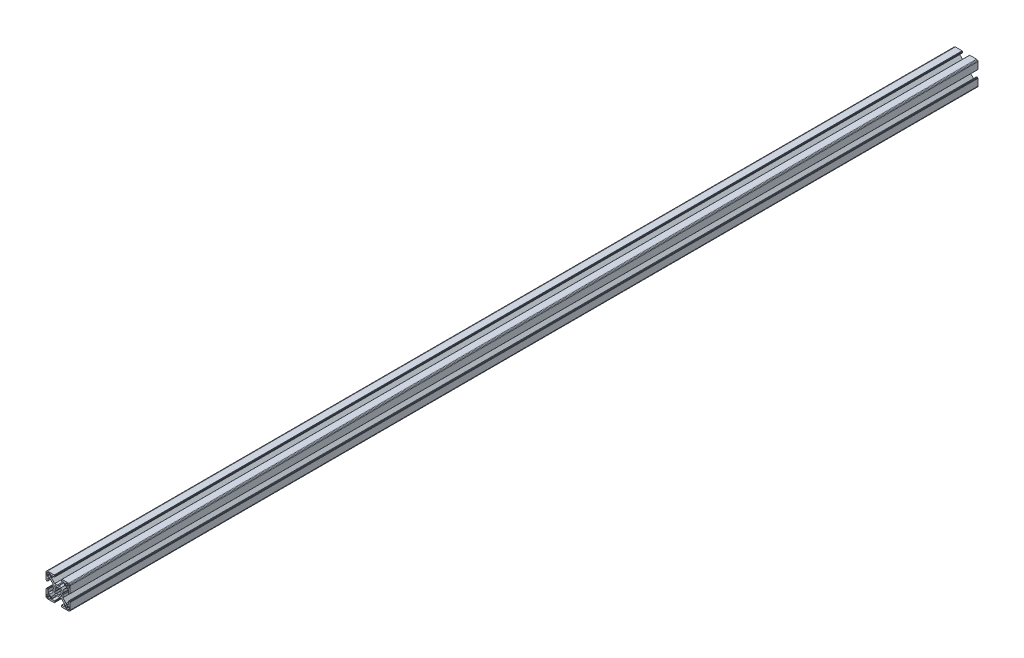
from build123d import *

# Parameters (mm, degrees)
BOSS_EXTRUDE1_DEPTH = 1130


with BuildPart() as part:
    # Sketch1 → Boss-Extrude1 (new body)
    with BuildSketch(Plane.XY):
        Polygon((28.34729664, 29.969613999), (28.000000864, 29.999999329), (19.750000909, 29.999999329), (19.715268165, 29.996961355), (19.681595266, 29.987938702), (19.649999216, 29.973205179), (19.621443003, 29.953207821), (19.596790895, 29.928557575), (19.576793537, 29.899999499), (19.562061876, 29.868405312), (19.55303736, 29.834728688), (19.549999386, 29.799999669), (19.549999386, 29.699999839), (19.546961412, 29.665268958), (19.537936896, 29.631596059), (19.523203373, 29.599998146), (19.503207877, 29.571441934), (19.478557631, 29.546789825), (19.449999556, 29.526794329), (19.418403506, 29.512060806), (19.384728745, 29.503038153), (19.349999726, 29.500000179), (19.249999896, 29.500000179), (19.215267517, 29.496958527), (19.181592755, 29.487935874), (19.149996706, 29.47320235), (19.12143863, 29.453206855), (19.096788384, 29.428554746), (19.076791026, 29.399996671), (19.062057503, 29.368402484), (19.05303485, 29.334725859), (19.049996876, 29.299998703), (19.049996876, 28.39999837), (19.059110798, 28.29580945), (19.08618062, 28.194785165), (19.13038119, 28.099997016), (19.190369539, 28.014324653), (19.264324002, 27.94037019), (19.349996366, 27.88038184), (19.444784515, 27.836181271), (19.545806937, 27.809111449), (19.650010894, 27.799984574), (23.050010706, 27.799984574), (23.084741588, 27.7969466), (23.118414487, 27.787923946), (23.150012399, 27.773190423), (23.178568612, 27.753193065), (23.203220721, 27.728542819), (23.223218079, 27.699984744), (23.237949739, 27.668386831), (23.246974255, 27.634713932), (23.25001142, 27.59998608), (23.25001142, 25.049987618), (19.204474482, 20.999982084), (15.900007876, 20.999982084), (15.000008474, 20.48483404), (14.10000814, 20.999982084), (10.795543398, 20.999982084), (7.997342887, 23.801274731), (6.750011387, 25.049984589), (6.750011387, 27.599983051), (6.753049362, 27.634713932), (6.762072946, 27.668386831), (6.776805538, 27.699984744), (6.796801965, 27.728542819), (6.821454073, 27.753193065), (6.850011218, 27.773190423), (6.881607267, 27.787923946), (6.915282029, 27.7969466), (6.950011048, 27.799984574), (10.350011791, 27.799984574), (10.45420071, 27.809098497), (10.555223133, 27.836168318), (10.650011282, 27.880368888), (10.735683645, 27.940357238), (10.809638108, 28.014311701), (10.869626458, 28.099984064), (10.913827027, 28.194772213), (10.940895918, 28.295796498), (10.950010772, 28.399985417), (10.950010772, 29.299985751), (10.946974575, 29.334739239), (10.93795065, 29.368415522), (10.923215933, 29.400009153), (10.903218427, 29.428566473), (10.878566319, 29.45321765), (10.849999264, 29.473204166), (10.818403214, 29.487937689), (10.784728453, 29.496960342), (10.749999434, 29.500000179), (10.649999604, 29.500000179), (10.615270585, 29.503038153), (10.581595823, 29.512060806), (10.549999774, 29.526794329), (10.521441698, 29.546789825), (10.496791452, 29.571441934), (10.476795025, 29.599998146), (10.462061502, 29.631596059), (10.453037918, 29.665268958), (10.449999943, 29.699999839), (10.449999943, 29.799999669), (10.446961969, 29.834728688), (10.437938385, 29.868405312), (10.423205793, 29.899999499), (10.403208435, 29.928557575), (10.378557257, 29.953207821), (10.350000113, 29.973205179), (10.318404064, 29.987938702), (10.284729302, 29.996961355), (10.250000283, 29.999999329), (1.999999397, 29.999999329), (1.652702689, 29.969613999), (1.315958682, 29.879383743), (0.999999233, 29.732050374), (0.714424066, 29.532089829), (0.467910431, 29.285576195), (0.267948955, 28.999999166), (0.120614655, 28.684040532), (0.030384399, 28.34729664), (0, 28.000000864), (0, 19.750000909), (0.003037974, 19.715268165), (0.012061559, 19.681595266), (0.026795082, 19.649999216), (0.046790577, 19.621441141), (0.071442686, 19.596789032), (0.09999983, 19.576793537), (0.13159588, 19.562060013), (0.165270641, 19.55303736), (0.19999966, 19.549999386), (0.299999461, 19.549999386), (0.334728509, 19.546959549), (0.368403242, 19.537936896), (0.399999321, 19.523203373), (0.428556465, 19.503207877), (0.453208573, 19.478555769), (0.473204069, 19.449997693), (0.487937592, 19.418403506), (0.496961176, 19.384728745), (0.499999151, 19.349999726), (0.499999151, 19.249998033), (0.503038056, 19.215269014), (0.512060709, 19.181594253), (0.526794232, 19.150000066), (0.546790194, 19.121441524), (0.571441837, 19.096789882), (0.60000029, 19.076794925), (0.631595686, 19.062061999), (0.665270619, 19.053039982), (0.700000626, 19.050000801), (1.60000096, 19.050000801), (1.704189879, 19.059116587), (1.805213233, 19.086186409), (1.90000045, 19.130385115), (1.985673745, 19.190375328), (2.059627277, 19.264327928), (2.119616325, 19.350002154), (2.163816196, 19.444788441), (2.190886018, 19.545812726), (2.200000872, 19.650001645), (2.200000872, 23.050001457), (2.203039777, 23.084732338), (2.212062431, 23.118405237), (2.226795954, 23.15000315), (2.246792381, 23.178559362), (2.271443558, 23.203211471), (2.300000702, 23.223206967), (2.331596752, 23.23794049), (2.365271513, 23.246965006), (2.400001464, 23.250001117), (4.950000857, 23.250001117), (7.997332093, 20.202670812), (8.995535423, 19.204467788), (8.995535423, 15.900001182), (9.515148227, 15.00000178), (8.995535423, 14.100002378), (8.995535423, 10.795536704), (4.950000857, 6.750002138), (2.400001464, 6.750002138), (2.365271513, 6.753040112), (2.331596752, 6.762063697), (2.300000702, 6.77679722), (2.271443558, 6.796793647), (2.246792381, 6.821444824), (2.226795954, 6.850001968), (2.212062431, 6.881598018), (2.203039777, 6.915272779), (2.200000872, 6.950002729), (2.200000872, 10.350002542), (2.190896812, 10.454174265), (2.16382699, 10.555197618), (2.119627119, 10.649984836), (2.059638071, 10.735658131), (1.985684539, 10.809611663), (1.900011244, 10.869600944), (1.805224027, 10.913800582), (1.704200673, 10.940870404), (1.600011754, 10.949986189), (0.70001142, 10.949986189), (0.665281355, 10.946948596), (0.631606253, 10.937926283), (0.600010578, 10.923193954), (0.571451747, 10.903199537), (0.546799638, 10.87854836), (0.526794232, 10.850000195), (0.512060709, 10.818404146), (0.503038056, 10.784730315), (0.499999151, 10.750000365), (0.499999151, 10.650000535), (0.496961176, 10.615270585), (0.487937592, 10.581596754), (0.473204069, 10.550000705), (0.453208573, 10.521443561), (0.428556465, 10.496791452), (0.399999321, 10.476795956), (0.368403242, 10.462062433), (0.334728509, 10.453038849), (0.299999461, 10.449999943), (0.19999966, 10.449999943), (0.165270641, 10.446961969), (0.13159588, 10.437939316), (0.09999983, 10.423205793), (0.071442686, 10.403209366), (0.046790577, 10.378558189), (0.026795082, 10.350000113), (0.012061559, 10.318404064), (0.003037974, 10.284729302), (0, 10.250000283), (0, 1.999999397), (0.030384399, 1.652702689), (0.120614655, 1.315958682), (0.267948955, 0.999999233), (0.467910431, 0.714424066), (0.714424066, 0.467910431), (0.999999233, 0.267948955), (1.315958682, 0.120614655), (1.652702689, 0.030384399), (1.999999397, 0), (10.250000283, 0), (10.284729302, 0.003037974), (10.318404064, 0.012061559), (10.350000113, 0.026795082), (10.378557257, 0.046790577), (10.403208435, 0.071442686), (10.423205793, 0.09999983), (10.437938385, 0.13159588), (10.446961969, 0.165270641), (10.449999943, 0.19999966), (10.449999943, 0.300000422), (10.453037918, 0.334729441), (10.462061502, 0.368404202), (10.476795025, 0.400000252), (10.496791452, 0.428557396), (10.521441698, 0.453208573), (10.549999774, 0.473205), (10.581595823, 0.487938523), (10.615270585, 0.496961176), (10.649999604, 0.500000082), (10.749999434, 0.500000082), (10.784728453, 0.503038056), (10.818403214, 0.512060709), (10.849999264, 0.526794232), (10.878547894, 0.546800104), (10.903198606, 0.571451747), (10.923194493, 0.6000102), (10.93792742, 0.631606528), (10.946949437, 0.66528146), (10.950010772, 0.699984975), (10.950010772, 1.599985308), (10.940895918, 1.704174228), (10.913827027, 1.805197581), (10.869626458, 1.89998573), (10.809638108, 1.985658094), (10.735683645, 2.059612557), (10.650011282, 2.119600674), (10.555223133, 2.163801476), (10.45420071, 2.190870367), (10.350011791, 2.199985221), (6.950011048, 2.199985221), (6.915282029, 2.203024126), (6.881607267, 2.212046779), (6.850011218, 2.226780302), (6.821454073, 2.246776729), (6.796801965, 2.271427907), (6.776805538, 2.299985982), (6.762072946, 2.331582032), (6.753049362, 2.365256793), (6.750011387, 2.399985812), (6.750011387, 4.949985206), (9.787457566, 7.990785077), (10.795545277, 8.999985833), (14.100010019, 8.999985833), (15.000010353, 9.515133877), (15.900009756, 8.999985833), (19.204476361, 8.999985833), (20.21256413, 7.990786065), (23.25001142, 4.949988235), (23.25001142, 2.399988841), (23.246974255, 2.365256793), (23.237949739, 2.331582032), (23.223218079, 2.299985982), (23.203220721, 2.271427907), (23.178568612, 2.246776729), (23.150012399, 2.226780302), (23.118414487, 2.212046779), (23.084741588, 2.203024126), (23.050010706, 2.199985221), (19.650010894, 2.199985221), (19.545806937, 2.190883319), (19.444784515, 2.163814428), (19.349996366, 2.119613626), (19.264324002, 2.059625509), (19.190369539, 1.985671046), (19.13038119, 1.899998682), (19.08618062, 1.805210533), (19.059110798, 1.70418718), (19.049996876, 1.599998261), (19.049996876, 0.699997927), (19.053035506, 0.665268966), (19.062058795, 0.631594374), (19.076792915, 0.599998603), (19.096790813, 0.571440905), (19.121441524, 0.546790194), (19.149999978, 0.526794306), (19.181596306, 0.51206138), (19.215271238, 0.503039363), (19.249999896, 0.500000082), (19.349999726, 0.500000082), (19.384728745, 0.496961176), (19.418403506, 0.487938523), (19.449999556, 0.473205), (19.478557631, 0.453208573), (19.503207877, 0.428557396), (19.523203373, 0.400000252), (19.537936896, 0.368404202), (19.546961412, 0.334729441), (19.549999386, 0.300000422), (19.549999386, 0.19999966), (19.55303736, 0.165270641), (19.562061876, 0.13159588), (19.576793537, 0.09999983), (19.596789964, 0.071441755), (19.621442072, 0.046789646), (19.649998285, 0.02679415), (19.681594335, 0.012060627), (19.715267234, 0.003037043), (19.750000909, 0), (28.000000864, 0), (28.34729664, 0.030384399), (28.684040532, 0.120614655), (28.999999166, 0.267948955), (29.285576195, 0.467910431), (29.532089829, 0.714424066), (29.732050374, 0.999999233), (29.879383743, 1.315958682), (29.969613999, 1.652702689), (29.999999329, 1.999999397), (29.999999329, 10.250000283), (29.996974806, 10.284715361), (29.987951516, 10.318389952), (29.973217396, 10.349985723), (29.953219499, 10.378543421), (29.928568787, 10.403194133), (29.899999499, 10.423205793), (29.868405312, 10.437939316), (29.834728688, 10.446961969), (29.799999669, 10.449999943), (29.699999839, 10.449999943), (29.664909937, 10.453400043), (29.631233313, 10.462423628), (29.599637263, 10.477157151), (29.57108105, 10.497152646), (29.546427079, 10.521804755), (29.526433446, 10.550361899), (29.511699923, 10.581957949), (29.502675407, 10.615631779), (29.499637433, 10.650361729), (29.499637433, 10.750361559), (29.49697202, 10.784715548), (29.487949367, 10.818389378), (29.473215844, 10.849985428), (29.453220348, 10.878542572), (29.428568239, 10.90319468), (29.400010164, 10.923190176), (29.368415977, 10.937923699), (29.334741215, 10.946947284), (29.300012197, 10.949986189), (28.400011863, 10.949986189), (28.29581215, 10.9408876), (28.194787865, 10.913817778), (28.099999716, 10.86961814), (28.014327352, 10.809628859), (27.940374752, 10.735675327), (27.880384539, 10.650002032), (27.836185833, 10.555214814), (27.809114148, 10.454191461), (27.800000225, 10.350002542), (27.800000225, 6.950002729), (27.796962251, 6.915272779), (27.787939598, 6.881598018), (27.773206075, 6.850001968), (27.753208716, 6.821444824), (27.728558471, 6.796793647), (27.700000395, 6.77679722), (27.668404345, 6.762063697), (27.634729584, 6.753040112), (27.599998702, 6.750002138), (25.05000024, 6.750002138), (23.809199132, 7.99080223), (21.004464477, 10.795534588), (21.004464477, 14.100000262), (20.484851673, 14.999999665), (21.004464477, 15.899999067), (21.004464477, 19.204465672), (25.05000024, 23.250001117), (27.599998702, 23.250001117), (27.634729584, 23.246965006), (27.668404345, 23.23794049), (27.700000395, 23.223206967), (27.728558471, 23.203211471), (27.753208716, 23.178559362), (27.773206075, 23.15000315), (27.787939598, 23.118405237), (27.796962251, 23.084732338), (27.800000225, 23.050001457), (27.800000225, 19.650001645), (27.809114148, 19.545812726), (27.836185833, 19.444788441), (27.880384539, 19.350002154), (27.940370508, 19.264323684), (28.014323108, 19.190371084), (28.099995472, 19.130380872), (28.194783621, 19.086182165), (28.295807906, 19.059112343), (28.400001069, 19.050000801), (29.300001402, 19.050000801), (29.334730421, 19.053040638), (29.368405183, 19.062063291), (29.39999937, 19.076796814), (29.42819671, 19.097149726), (29.452848353, 19.1218023), (29.472843309, 19.150360754), (29.487576235, 19.181955219), (29.496598252, 19.215630151), (29.499637433, 19.250359227), (29.499637433, 19.35036092), (29.502675407, 19.385089939), (29.511699923, 19.4187647), (29.526433446, 19.450358887), (29.546427079, 19.478916963), (29.57108105, 19.503569071), (29.599637263, 19.523564567), (29.631233313, 19.53829809), (29.664909937, 19.547320743), (29.699999839, 19.549999386), (29.799999669, 19.549999386), (29.834728688, 19.55303736), (29.868405312, 19.562060013), (29.899999499, 19.576793537), (29.928557575, 19.596789032), (29.953207821, 19.621441141), (29.973205179, 19.649999216), (29.987938702, 19.681595266), (29.996961355, 19.715268165), (29.999999329, 19.750000909), (29.999999329, 28.000000864), (29.969613999, 28.34729664), (29.879383743, 28.684040532), (29.732050374, 28.999999166), (29.532089829, 29.285576195), (29.285576195, 29.532089829), (28.999999166, 29.732050374), (28.684040532, 29.879383743), align=None)
        Polygon((1.299998723, 25.499999523), (1.299998723, 27.699999511), (1.312309876, 27.856435627), (1.348942518, 28.009016067), (1.408992335, 28.153989464), (1.490981318, 28.287785128), (1.592892222, 28.407108039), (1.71221327, 28.50901708), (1.846008119, 28.591006994), (1.9909814, 28.651056811), (2.143563703, 28.687689453), (2.299998887, 28.699999675), (4.499998875, 28.699999675), (4.656434059, 28.687689453), (4.809016362, 28.651056811), (4.953989759, 28.591006994), (5.087784491, 28.50901708), (5.207106471, 28.407108039), (5.309016444, 28.287785128), (5.391005427, 28.153989464), (5.451056175, 28.009016067), (5.487687886, 27.856435627), (5.499999039, 27.699999511), (5.499999039, 25.499999523), (5.487687886, 25.34356527), (5.451056175, 25.190982968), (5.391005427, 25.04600957), (5.309016444, 24.912213907), (5.207106471, 24.792892858), (5.087784491, 24.690981954), (4.953989759, 24.60899204), (4.809016362, 24.548944086), (4.656434059, 24.512309581), (4.499998875, 24.499999359), (2.299998887, 24.499999359), (2.143563703, 24.512309581), (1.9909814, 24.548944086), (1.846008119, 24.60899204), (1.71221327, 24.690981954), (1.592892222, 24.792892858), (1.490981318, 24.912213907), (1.408992335, 25.04600957), (1.348942518, 25.190982968), (1.312309876, 25.34356527), align=None, mode=Mode.SUBTRACT)
        Polygon((25.34356527, 28.687689453), (25.499999523, 28.699999675), (27.699999511, 28.699999675), (27.856435627, 28.687689453), (28.009017929, 28.651056811), (28.153991327, 28.591006994), (28.28778699, 28.50901708), (28.407108039, 28.407108039), (28.50901708, 28.287785128), (28.591006994, 28.153989464), (28.651056811, 28.009016067), (28.687689453, 27.856435627), (28.700001538, 27.699999511), (28.700001538, 25.499999523), (28.687689453, 25.34356527), (28.651056811, 25.190982968), (28.591006994, 25.04600957), (28.50901708, 24.912213907), (28.407108039, 24.792892858), (28.28778699, 24.690981954), (28.153991327, 24.60899204), (28.009017929, 24.548944086), (27.856435627, 24.512309581), (27.699999511, 24.499999359), (25.499999523, 24.499999359), (25.34356527, 24.512309581), (25.190982968, 24.548944086), (25.04600957, 24.60899204), (24.912215769, 24.690981954), (24.792892858, 24.792892858), (24.690981954, 24.912213907), (24.608993903, 25.04600957), (24.548944086, 25.190982968), (24.512311444, 25.34356527), (24.500001222, 25.499999523), (24.500001222, 27.699999511), (24.512311444, 27.856435627), (24.548944086, 28.009016067), (24.608993903, 28.153989464), (24.690981954, 28.287785128), (24.792892858, 28.407108039), (24.912215769, 28.50901708), (25.04600957, 28.591006994), (25.190982968, 28.651056811), align=None, mode=Mode.SUBTRACT)
        Polygon((14.999999665, 18.649999052), (15.550030395, 18.608318642), (16.087498516, 18.484227359), (16.600128263, 18.280562013), (18.13592948, 19.518401474), (18.644984812, 19.11874488), (19.103571773, 18.662061542), (19.505336881, 18.154669553), (18.280562013, 16.600130126), (18.484227359, 16.087498516), (18.608318642, 15.550030395), (18.649999052, 14.999999665), (18.608318642, 14.449968934), (18.484227359, 13.912500814), (18.280562013, 13.399870135), (19.505336881, 11.845329776), (19.103571773, 11.337937787), (18.644984812, 10.881252587), (18.13592948, 10.481598787), (16.600128263, 11.719437316), (16.087498516, 11.515771039), (15.550030395, 11.391680688), (14.999999665, 11.349999346), (14.449968934, 11.391680688), (13.912500814, 11.515771039), (13.399870135, 11.719437316), (11.864069849, 10.481598787), (11.355013587, 10.881252587), (10.896427557, 11.337937787), (10.494662449, 11.845329776), (11.719438247, 13.399870135), (11.515771039, 13.912500814), (11.391680688, 14.449968934), (11.349999346, 14.999999665), (11.391680688, 15.550030395), (11.515771039, 16.087498516), (11.719438247, 16.600130126), (10.494662449, 18.154669553), (10.896427557, 18.662061542), (11.355013587, 19.11874488), (11.864069849, 19.518401474), (13.399870135, 18.280562013), (13.912500814, 18.484227359), (14.449968934, 18.608318642), align=None, mode=Mode.SUBTRACT)
        Polygon((4.499998875, 1.299999771), (2.299998887, 1.299999771), (2.143563703, 1.312310807), (1.9909814, 1.348942518), (1.846008119, 1.408992335), (1.71221327, 1.490982249), (1.592892222, 1.592892222), (1.490981318, 1.712214202), (1.408992335, 1.846008934), (1.348942518, 1.990982331), (1.312309876, 2.143564634), (1.299998723, 2.299998887), (1.299998723, 4.499999806), (1.312309876, 4.656434059), (1.348942518, 4.809017293), (1.408992335, 4.95399069), (1.490981318, 5.087785423), (1.592892222, 5.207106471), (1.71221327, 5.309017375), (1.846008119, 5.391006358), (1.9909814, 5.451056175), (2.143563703, 5.487688817), (2.299998887, 5.49999997), (4.499998875, 5.49999997), (4.656434059, 5.487688817), (4.809016362, 5.451056175), (4.953989759, 5.391006358), (5.087784491, 5.309017375), (5.207106471, 5.207106471), (5.309016444, 5.087785423), (5.391005427, 4.95399069), (5.451056175, 4.809017293), (5.487687886, 4.656434059), (5.499999039, 4.499999806), (5.499999039, 2.299998887), (5.487687886, 2.143564634), (5.451056175, 1.990982331), (5.391005427, 1.846008934), (5.309016444, 1.712214202), (5.207106471, 1.592892222), (5.087784491, 1.490982249), (4.953989759, 1.408992335), (4.809016362, 1.348942518), (4.656434059, 1.312310807), align=None, mode=Mode.SUBTRACT)
        Polygon((27.699999511, 1.299999771), (25.499999523, 1.299999771), (25.34356527, 1.312310807), (25.190982968, 1.348942518), (25.04600957, 1.408992335), (24.912215769, 1.490982249), (24.792892858, 1.592892222), (24.690981954, 1.712214202), (24.608993903, 1.846008934), (24.548944086, 1.990982331), (24.512311444, 2.143564634), (24.500001222, 2.299998887), (24.500001222, 4.499999806), (24.512311444, 4.656434059), (24.548944086, 4.809017293), (24.608993903, 4.95399069), (24.690981954, 5.087785423), (24.792892858, 5.207106471), (24.912215769, 5.309017375), (25.04600957, 5.391006358), (25.190982968, 5.451056175), (25.34356527, 5.487688817), (25.499999523, 5.49999997), (27.699999511, 5.49999997), (27.856435627, 5.487688817), (28.009017929, 5.451056175), (28.153991327, 5.391006358), (28.28778699, 5.309017375), (28.407108039, 5.207106471), (28.50901708, 5.087785423), (28.591006994, 4.95399069), (28.651056811, 4.809017293), (28.687689453, 4.656434059), (28.700001538, 4.499999806), (28.700001538, 2.299998887), (28.687689453, 2.143564634), (28.651056811, 1.990982331), (28.591006994, 1.846008934), (28.50901708, 1.712214202), (28.407108039, 1.592892222), (28.28778699, 1.490982249), (28.153991327, 1.408992335), (28.009017929, 1.348942518), (27.856435627, 1.312310807), align=None, mode=Mode.SUBTRACT)
    extrude(amount=-BOSS_EXTRUDE1_DEPTH)


solid = part.part
